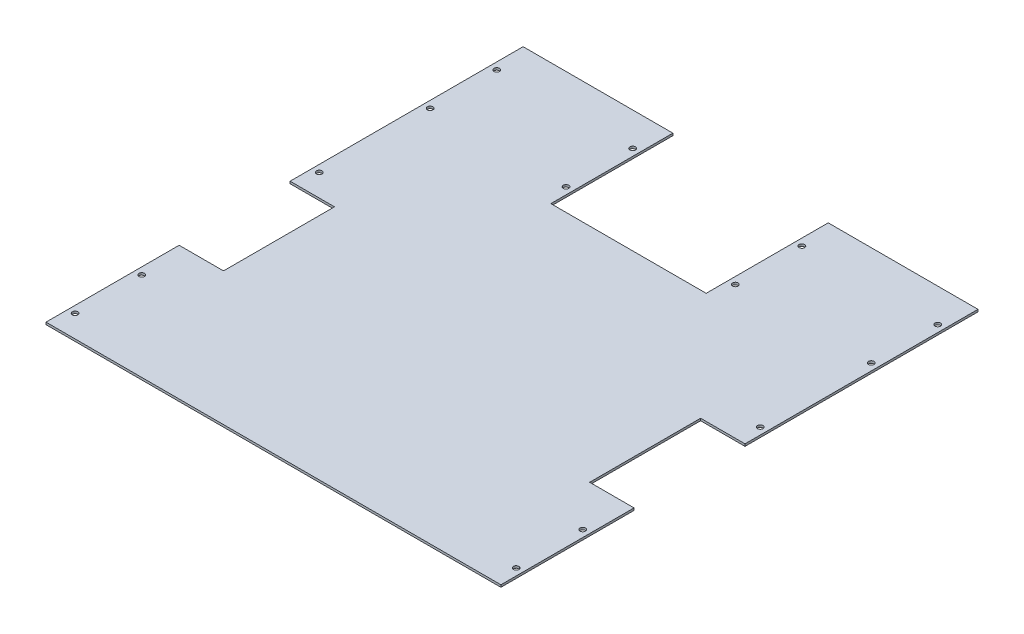
from build123d import *

# Parameters (mm, degrees)
BOSS_EXTRUDE1_DEPTH = 2.54
SKETCH2_R           = 3.175
CUT_EXTRUDE1_DEPTH  = 3.54


with BuildPart() as part:
    # Sketch1 → Boss-Extrude1 (new body)
    with BuildSketch(Plane(origin=(0, 0, 0), x_dir=(1, 0, 0), z_dir=(0, 1, 0))):
        Polygon((0, 279.4), (0, 546.1), (171.45, 546.1), (171.45, 406.4), (349.25, 406.4), (349.25, 546.1), (520.7, 546.1), (520.7, 279.4), (469.9, 279.4), (469.9, 152.4), (520.7, 152.4), (520.7, 0), (0, 0), (0, 152.4), (50.8, 152.4), (50.8, 279.4), align=None)
    extrude(amount=BOSS_EXTRUDE1_DEPTH)

    # Sketch2 → Cut-Extrude1 (cut, through all)
    with BuildSketch(Plane(origin=(0, 2.54, 0), x_dir=(1, 0, 0), z_dir=(0, 1, 0))):
        with Locations((7.9375, 508)):
            Circle(SKETCH2_R)
        with Locations((163.5125, 508)):
            Circle(SKETCH2_R)
        with Locations((7.9375, 431.8)):
            Circle(SKETCH2_R)
        with Locations((163.5125, 431.8)):
            Circle(SKETCH2_R)
        with Locations((7.9375, 304.8)):
            Circle(SKETCH2_R)
        with Locations((7.9375, 101.6)):
            Circle(SKETCH2_R)
        with Locations((7.9375, 25.4)):
            Circle(SKETCH2_R)
        with Locations((512.7625, 25.4)):
            Circle(SKETCH2_R)
        with Locations((512.7625, 101.6)):
            Circle(SKETCH2_R)
        with Locations((512.7625, 304.8)):
            Circle(SKETCH2_R)
        with Locations((357.1875, 431.8)):
            Circle(SKETCH2_R)
        with Locations((512.7625, 431.8)):
            Circle(SKETCH2_R)
        with Locations((357.1875, 508)):
            Circle(SKETCH2_R)
        with Locations((512.7625, 508)):
            Circle(SKETCH2_R)
    extrude(amount=-CUT_EXTRUDE1_DEPTH, mode=Mode.SUBTRACT)


solid = part.part
